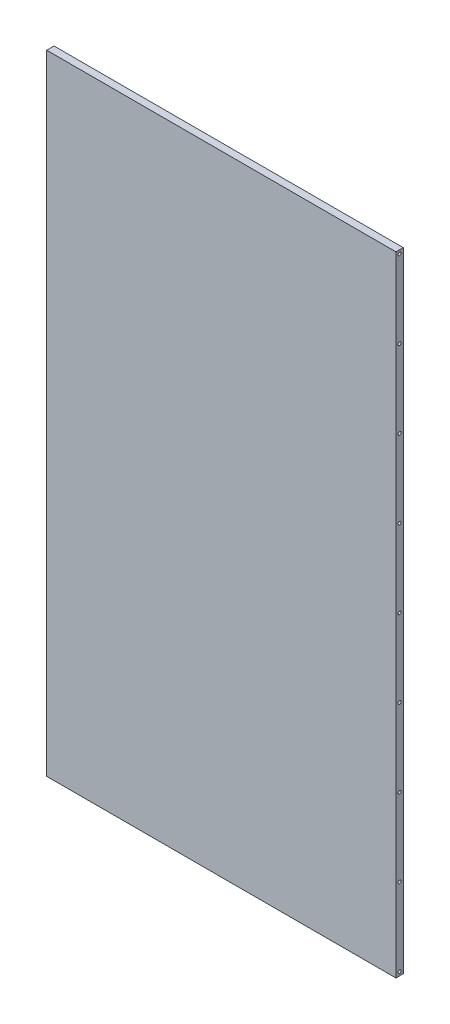
from build123d import *

# Parameters (mm, degrees)
SKETCH1_W           = 286.0056
SKETCH1_H           = 515
BOSS_EXTRUDE1_DEPTH = 5.9944
LPATTERN1_COUNT     = 5
LPATTERN1_PITCH     = 63.625
LPATTERN1_COL_COUNT = 5
LPATTERN1_COL_PITCH = 63.625


with BuildPart() as part:
    # Sketch1 → Boss-Extrude1 (new body)
    with BuildSketch(Plane.XY):
        with Locations((143.0028, 257.5)):
            Rectangle(SKETCH1_W, SKETCH1_H)
    extrude(amount=BOSS_EXTRUDE1_DEPTH)

    # Sketch2 → Tap Drill for M3x0.5 Tap1 (revolve, cut)
    with BuildSketch(Plane(origin=(286.0056, 257.5, 2.9972), x_dir=(0, 0, -1), z_dir=(0, 1, 0))):
        Polygon((0, 0), (0, 30.751075774), (1.25, 30), (1.25, 0), align=None)
    tap_drill_for_m3x0_5_tap1 = revolve(axis=Axis((292.3556, 257.5, 2.9972), (-1, 0, 0)), mode=Mode.SUBTRACT)

    # LPattern1: Tap Drill for M3x0.5 Tap1 ×5
    with Locations(*[(0, i * LPATTERN1_PITCH, 0) for i in range(1, LPATTERN1_COUNT)]):
        add(tap_drill_for_m3x0_5_tap1, mode=Mode.SUBTRACT)

    # LPattern1 col: Tap Drill for M3x0.5 Tap1 ×5
    with Locations(*[(0, -i * LPATTERN1_COL_PITCH, 0) for i in range(1, LPATTERN1_COL_COUNT)]):
        add(tap_drill_for_m3x0_5_tap1, mode=Mode.SUBTRACT)

    # Mirror1: Tap Drill for M3x0.5 Tap1 across plane
    add(tap_drill_for_m3x0_5_tap1.mirror(Plane(origin=(143.0028, 0, 0), x_dir=(0, 0, 1), z_dir=(1, 0, 0))), mode=Mode.SUBTRACT)

    # Mirror1 copy 1 sketch → Mirror1 copy 1 (revolve, cut)
    with BuildSketch(Plane(origin=(0, 321.125, 2.9972), x_dir=(0, 0, -1), z_dir=(0, 1, 0))):
        Polygon((0, 0), (0, -30.751075774), (1.25, -30), (1.25, 0), align=None)
    revolve(axis=Axis((-6.35, 321.125, 2.9972), (-1, 0, 0)), mode=Mode.SUBTRACT)

    # Mirror1 copy 2 sketch → Mirror1 copy 2 (revolve, cut)
    with BuildSketch(Plane(origin=(0, 384.75, 2.9972), x_dir=(0, 0, -1), z_dir=(0, 1, 0))):
        Polygon((0, 0), (0, -30.751075774), (1.25, -30), (1.25, 0), align=None)
    revolve(axis=Axis((-6.35, 384.75, 2.9972), (-1, 0, 0)), mode=Mode.SUBTRACT)

    # Mirror1 copy 3 sketch → Mirror1 copy 3 (revolve, cut)
    with BuildSketch(Plane(origin=(0, 448.375, 2.9972), x_dir=(0, 0, -1), z_dir=(0, 1, 0))):
        Polygon((0, 0), (0, -30.751075774), (1.25, -30), (1.25, 0), align=None)
    revolve(axis=Axis((-6.35, 448.375, 2.9972), (-1, 0, 0)), mode=Mode.SUBTRACT)

    # Mirror1 copy 4 sketch → Mirror1 copy 4 (revolve, cut)
    with BuildSketch(Plane(origin=(0, 512, 2.9972), x_dir=(0, 0, -1), z_dir=(0, 1, 0))):
        Polygon((0, 0), (0, -30.751075774), (1.25, -30), (1.25, 0), align=None)
    revolve(axis=Axis((-6.35, 512, 2.9972), (-1, 0, 0)), mode=Mode.SUBTRACT)

    # Mirror1 copy 5 sketch → Mirror1 copy 5 (revolve, cut)
    with BuildSketch(Plane(origin=(0, 193.875, 2.9972), x_dir=(0, 0, -1), z_dir=(0, 1, 0))):
        Polygon((0, 0), (0, -30.751075774), (1.25, -30), (1.25, 0), align=None)
    revolve(axis=Axis((-6.35, 193.875, 2.9972), (-1, 0, 0)), mode=Mode.SUBTRACT)

    # Mirror1 copy 6 sketch → Mirror1 copy 6 (revolve, cut)
    with BuildSketch(Plane(origin=(0, 130.25, 2.9972), x_dir=(0, 0, -1), z_dir=(0, 1, 0))):
        Polygon((0, 0), (0, -30.751075774), (1.25, -30), (1.25, 0), align=None)
    revolve(axis=Axis((-6.35, 130.25, 2.9972), (-1, 0, 0)), mode=Mode.SUBTRACT)

    # Mirror1 copy 7 sketch → Mirror1 copy 7 (revolve, cut)
    with BuildSketch(Plane(origin=(0, 66.625, 2.9972), x_dir=(0, 0, -1), z_dir=(0, 1, 0))):
        Polygon((0, 0), (0, -30.751075774), (1.25, -30), (1.25, 0), align=None)
    revolve(axis=Axis((-6.35, 66.625, 2.9972), (-1, 0, 0)), mode=Mode.SUBTRACT)

    # Mirror1 copy 8 sketch → Mirror1 copy 8 (revolve, cut)
    with BuildSketch(Plane(origin=(0, 3, 2.9972), x_dir=(0, 0, -1), z_dir=(0, 1, 0))):
        Polygon((0, 0), (0, -30.751075774), (1.25, -30), (1.25, 0), align=None)
    revolve(axis=Axis((-6.35, 3, 2.9972), (-1, 0, 0)), mode=Mode.SUBTRACT)


solid = part.part
